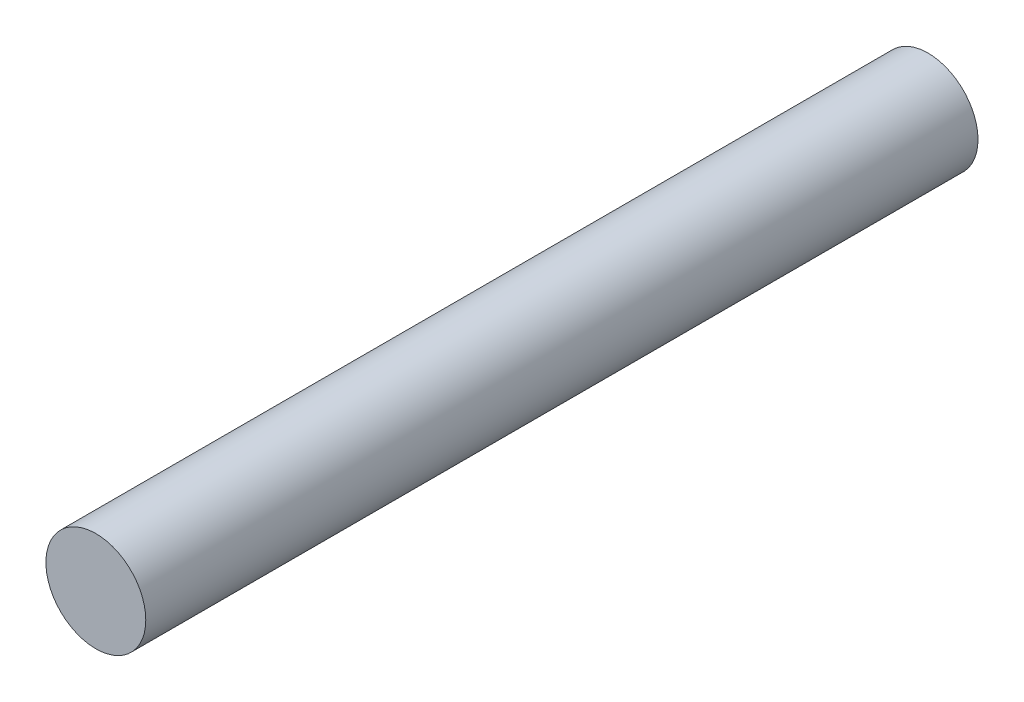
from build123d import *

# Parameters (mm, degrees)
SKETCH1_R           = 6
BOSS_EXTRUDE1_DEPTH = 50


with BuildPart() as part:
    # Sketch1 → Boss-Extrude1 (new body, symmetric)
    with BuildSketch(Plane.XY):
        Circle(SKETCH1_R)
    extrude(amount=BOSS_EXTRUDE1_DEPTH, both=True)


solid = part.part
